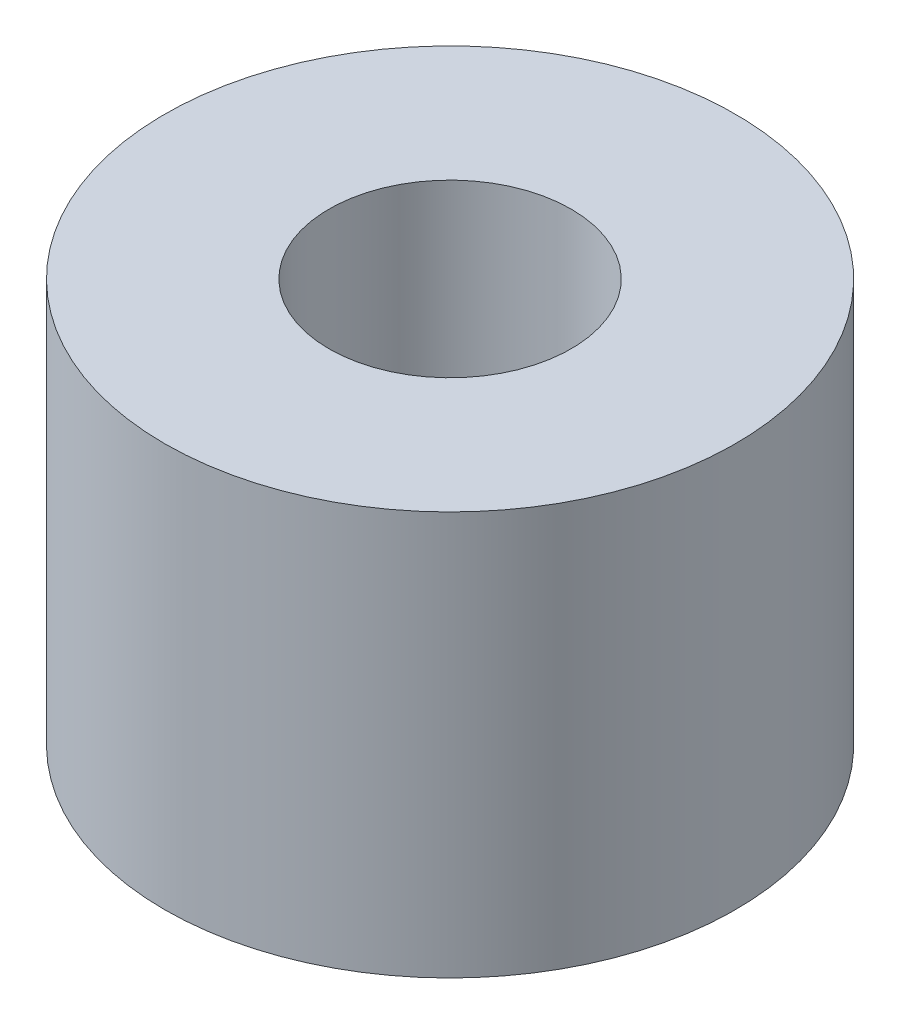
from build123d import *

# Parameters (mm, degrees)
SKETCH1_R           = 3.535533906
SKETCH1_R_2         = 1.5
BOSS_EXTRUDE1_DEPTH = 5


with BuildPart() as part:
    # Sketch1 → Boss-Extrude1 (new body)
    with BuildSketch(Plane(origin=(0, 0, 0), x_dir=(1, 0, 0), z_dir=(0, 1, 0))):
        Circle(SKETCH1_R)
        Circle(SKETCH1_R_2, mode=Mode.SUBTRACT)
    extrude(amount=BOSS_EXTRUDE1_DEPTH)


solid = part.part
